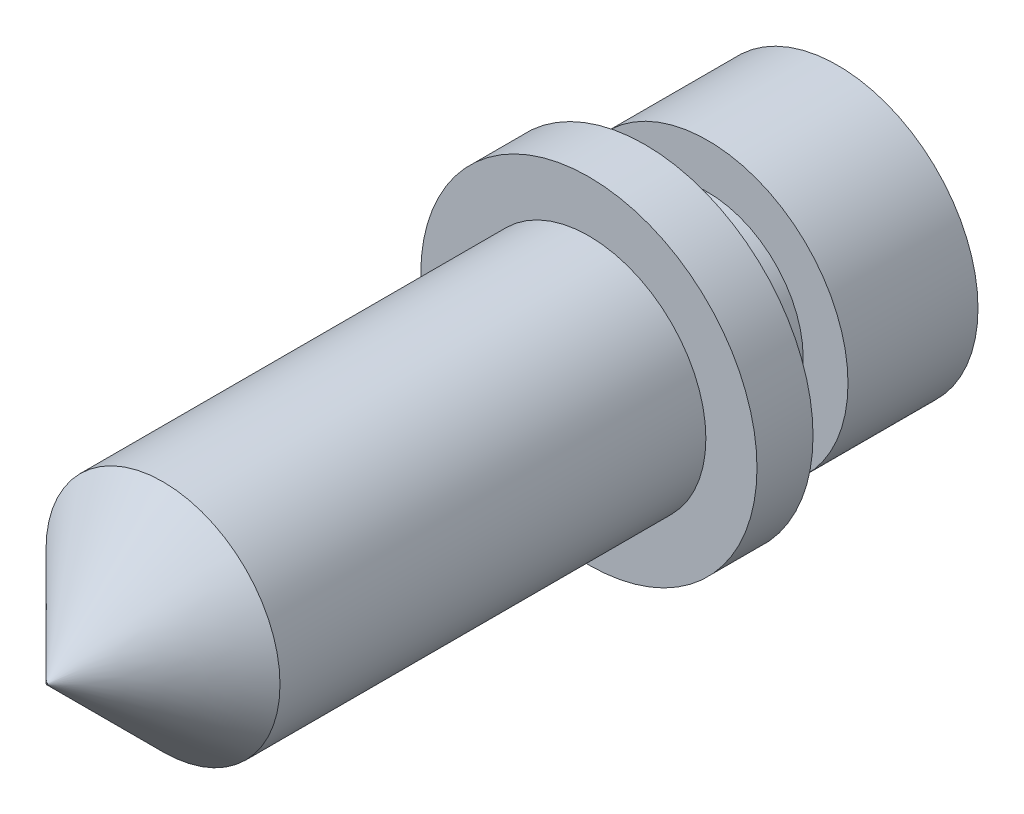
from build123d import *

# Parameters (mm, degrees)
SKETCH1_R           = 4.7625
BOSS_EXTRUDE1_DEPTH = 0.79375
SKETCH2_R           = 3.9751
BOSS_EXTRUDE2_DEPTH = 5.461
SKETCH3_R           = 3.3147
BOSS_EXTRUDE3_DEPTH = 12.065
SKETCH6_R           = 1.5875
CUT_EXTRUDE1_DEPTH  = 19.05
SKETCH10_W          = 1.27
SKETCH10_H          = 1.778
SKETCH11_R          = 0.0508
CUT_EXTRUDE3_DEPTH  = 0.0254
SKETCH9_R           = 0.02
CUT_EXTRUDE2_DEPTH  = 23.4028


with BuildPart() as part:
    # Sketch1 → Boss-Extrude1 (new body, symmetric)
    with BuildSketch(Plane.XY):
        Circle(SKETCH1_R)
    extrude(amount=BOSS_EXTRUDE1_DEPTH, both=True)

    # Sketch2 → Boss-Extrude2 (add)
    with BuildSketch(Plane(origin=(0, 0, -0.79375), x_dir=(-1, 0, 0), z_dir=(0, 0, -1))):
        with Locations(Location((0, 0, 0), (0, 0, 180))):  # turned: the seam where the file's is
            Circle(SKETCH2_R)
    extrude(amount=BOSS_EXTRUDE2_DEPTH)

    # Sketch3 → Boss-Extrude3 (add)
    with BuildSketch(Plane.XY.offset(0.79375)):
        Circle(SKETCH3_R)
    extrude(amount=BOSS_EXTRUDE3_DEPTH)

    # Sketch5 → Revolve1 (revolve)
    with BuildSketch(Plane(origin=(0, 0, 0), x_dir=(0, 0, -1), z_dir=(1, 0, 0)), mode=Mode.PRIVATE) as revolve1_sk:
        Polygon((-12.85875, 3.3147), (-16.17345, 0), (-12.85875, 0), align=None)
    revolve(revolve1_sk.sketch.rotate(Axis((0, 0, 0), (0, 0, 1)), 270), axis=Axis((0, 0, 0), (0, 0, 1)))  # turned: the seam where the file's is

    # Sketch6 → Cut-Extrude1 (cut)
    with BuildSketch(Plane(origin=(0, 0, -6.25475), x_dir=(-1, 0, 0), z_dir=(0, 0, -1))):
        Circle(SKETCH6_R)
    extrude(amount=-CUT_EXTRUDE1_DEPTH, mode=Mode.SUBTRACT)

    # Sketch10 → Cut-Revolve1 (revolve, cut)
    with BuildSketch(Plane(origin=(0, 0, 0), x_dir=(1, 0, 0), z_dir=(0, 1, 0)), mode=Mode.PRIVATE) as cut_revolve1_sk:
        with Locations((-3.3401, 1.68275)):
            Rectangle(SKETCH10_W, SKETCH10_H)
    revolve(cut_revolve1_sk.sketch.rotate(Axis((0, 0, 0), (0, 0, -1)), 180), axis=Axis((0, 0, 0), (0, 0, -1)), mode=Mode.SUBTRACT)  # turned: the seam where the file's is

    # Sketch11 → Cut-Extrude3 (cut)
    with BuildSketch(Plane.XY.offset(16.17345)):
        Circle(SKETCH11_R)
    extrude(amount=-CUT_EXTRUDE3_DEPTH, mode=Mode.SUBTRACT)

    # Sketch9 → Cut-Extrude2 (cut, through all)
    with BuildSketch(Plane(origin=(0, 0, -6.25475), x_dir=(-1, 0, 0), z_dir=(0, 0, -1))):
        Circle(SKETCH9_R)
    extrude(amount=-CUT_EXTRUDE2_DEPTH, mode=Mode.SUBTRACT)


solid = part.part
